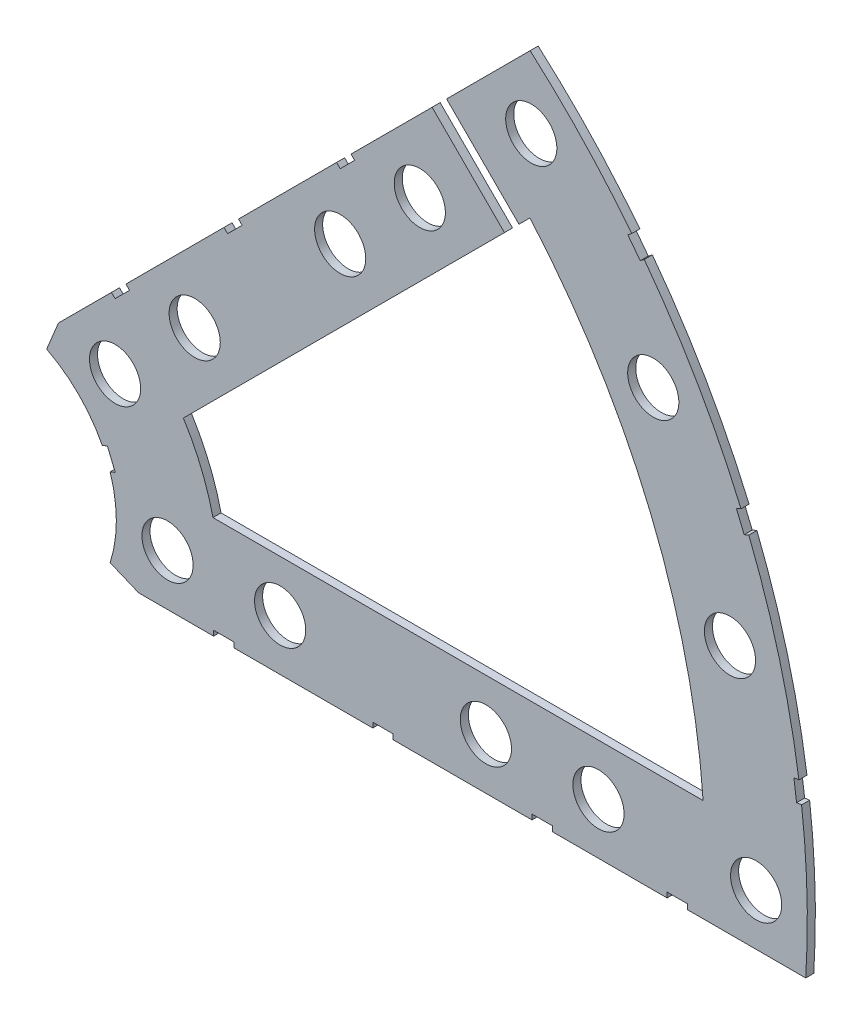
from build123d import *

# Parameters (mm, degrees)
BOSS_EXTRUDE1_DEPTH = 1
SKETCH2_R           = 3.175
CUT_EXTRUDE1_DEPTH  = 2
SKETCH3_W           = 2.54
SKETCH3_H           = 0.635
CUT_EXTRUDE2_DEPTH  = 2


with BuildPart() as part:
    # Sketch1 → Boss-Extrude1 (new body)
    with BuildSketch(Plane.XY):
        with BuildLine():
            Line((67.21146711, 76.191723231), (8.696654013, 17.676910134))
            Line((8.696654013, 17.676910134), (7.228954972, 14.133571205))
            ThreePointArc((7.228954972, 14.133571205), (14.666587579, 6.075099489), (15.105587123, -4.88230096))
            Line((15.105587123, -4.88230096), (18.648926052, -6.35))
            Line((18.648926052, -6.35), (101.401368334, -6.35))
            ThreePointArc((101.401368334, -6.35), (93.866160503, 38.880636728), (67.21146711, 76.191723231))
        make_face()
        with BuildLine():
            Line((88.672924278, 6.35), (27.86051193, 6.35))
            ThreePointArc((27.86051193, 6.35), (26.399857642, 10.93517908), (24.190484974, 15.210228852))
            Line((24.190484974, 15.210228852), (67.191354125, 58.211098004))
            ThreePointArc((67.191354125, 58.211098004), (82.13289044, 34.020557137), (88.672924278, 6.35))
        make_face(mode=Mode.SUBTRACT)
    extrude(amount=BOSS_EXTRUDE1_DEPTH)

    # Sketch2 → Cut-Extrude1 (cut, through all)
    with BuildSketch(Plane.XY.offset(1)):
        with Locations((22.225, 0)):
            Circle(SKETCH2_R)
        with Locations((36.195, 0)):
            Circle(SKETCH2_R)
        with Locations((61.722, 0)):
            Circle(SKETCH2_R)
        with Locations((75.692, 0)):
            Circle(SKETCH2_R)
        with Locations((95.25, 0)):
            Circle(SKETCH2_R)
        with Locations((15.715448212, 15.715448212)):
            Circle(SKETCH2_R)
        with Locations((25.593729945, 25.593729945)):
            Circle(SKETCH2_R)
        with Locations((43.644044748, 43.644044748)):
            Circle(SKETCH2_R)
        with Locations((53.522326482, 53.522326482)):
            Circle(SKETCH2_R)
        with Locations((92.004434954, 24.652514046)):
            Circle(SKETCH2_R)
        with Locations((82.48891971, 47.625)):
            Circle(SKETCH2_R)
        with Locations((67.351920908, 67.351920908)):
            Circle(SKETCH2_R)
    extrude(amount=-CUT_EXTRUDE1_DEPTH, mode=Mode.SUBTRACT)

    # Sketch3 → Cut-Extrude2 (cut, through all)
    with BuildSketch(Plane.XY.offset(1)):
        Polygon((15.266435406, 24.246691527), (17.06248663, 26.042742751), (17.511499436, 25.593729945), (15.715448212, 23.797678721), align=None)
        Polygon((44.991083167, 53.971339288), (43.195031942, 52.175288063), (43.644044748, 51.726275257), (45.440095973, 53.522326482), align=None)
        with Locations((29.21, -6.0325)):
            Rectangle(SKETCH3_W, SKETCH3_H)
        with Locations((68.707, -6.0325)):
            Rectangle(SKETCH3_W, SKETCH3_H)
        Polygon((29.230733674, 38.210989795), (31.026784898, 40.007041019), (31.475797704, 39.558028213), (29.67974648, 37.761976989), align=None)
        Polygon((55.048970022, 64.029226143), (56.845021246, 65.825277367), (65.825277367, 56.845021246), (64.029226143, 55.048970022), align=None)
        with Locations((48.9585, -6.0325)):
            Rectangle(SKETCH3_W, SKETCH3_H)
        with Locations((85.471, -6.0325)):
            Rectangle(SKETCH3_W, SKETCH3_H)
        Polygon((99.935462164, 14.437711971), (100.266998693, 11.919442024), (101.526133667, 12.085210288), (101.194597138, 14.603480236), align=None)
        Polygon((93.765504959, 37.464305742), (94.938831965, 37.950313702), (93.966816047, 40.296967714), (92.793489041, 39.810959755), align=None)
        Polygon((79.327792988, 62.471156422), (80.874047017, 60.456038938), (81.88160576, 61.229165953), (80.33535173, 63.244283437), align=None)
        Polygon((13.593916116, 7.005422516), (14.565932035, 4.658768503), (15.739259041, 5.144776462), (14.767243123, 7.491430475), align=None)
    extrude(amount=-CUT_EXTRUDE2_DEPTH, mode=Mode.SUBTRACT)


solid = part.part
